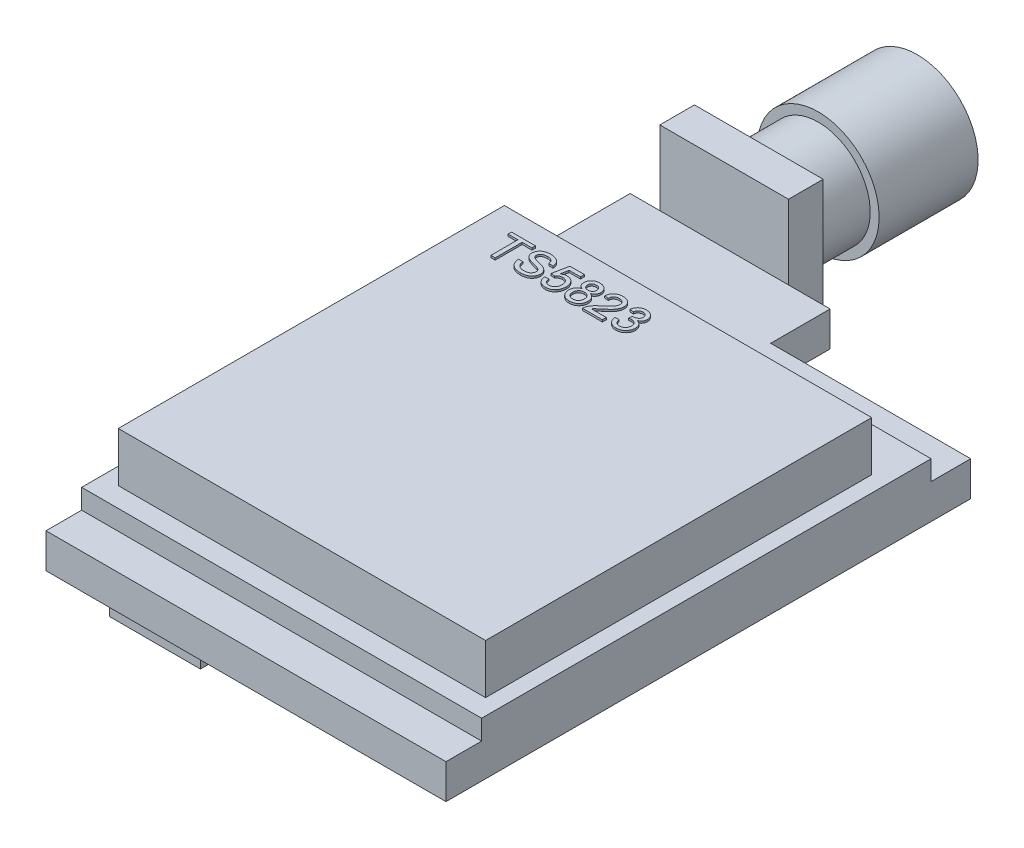
from build123d import *

# Parameters (mm, degrees)
SKETCH_1_W                 = 20.2
SKETCH_1_H                 = 29.5
MAIN_PCB_DEPTH             = 1.75
SKETCH_2_W                 = 20.2
SKETCH_2_H                 = 22.7
RADIO_MODULE_PCB_DEPTH     = 1
SKETCH_3_W                 = 18.55
SKETCH_3_H                 = 19.5
RADIO_MODULE_DEPTH         = 2.5
SKETCH_4_W                 = 6.5
SKETCH_4_H                 = 6.5
ANTENNA_SOCKET_DEPTH       = 1.75
SKETCH_5_R                 = 2.625
ANTENNA_RING_DEPTH         = 3
SKETCH_6_R                 = 3.075
ANTENNA_NUT_DEPTH          = 5
SKETCH_7_R                 = 2.075
SKETCH_7_R_2               = 0.5
ANTENNA_CONNECTOR_DEPTH    = 2
SKETCH_9_W                 = 1
SKETCH_9_H                 = 4
ANTENNA_LEG_DEPTH          = 1
NAME_TS5823_DEPTH          = 0.1
SKETCH_18_W                = 10.1
SKETCH_18_H                = 3
PCB_CUT_OUT_DEPTH          = 6.5
SKETCH_19_W                = 5.5
SKETCH_19_H                = 9.4
EXTRUDE_1_DEPTH            = 2.5
SKETCH_21_W                = 2
SKETCH_21_H                = 0.8
JIMPES_SWITCH_DEPTH        = 0.4
PATTERN_LINEAR_1_COUNT     = 6
PATTERN_LINEAR_1_PITCH     = 1.5
SKETCH_22_W                = 4.6
SKETCH_22_H                = 7.2
EXTRUDE_2_DEPTH            = 3
SKETCH_23_W                = 6.2
SKETCH_23_H                = 2
CUT_EXTRUDE_4_DEPTH        = 4
SKETCH_24_W                = 0.4
SKETCH_24_H                = 0.6
EXTRUDE_3_DEPTH            = 3
PATTERN_LINEAR_2_COUNT     = 3
PATTERN_LINEAR_2_PITCH     = 1
PATTERN_LINEAR_2_COL_COUNT = 3
PATTERN_LINEAR_2_COL_PITCH = 1


with BuildPart() as part:
    # Эскиз1 → main-pcb (new body)
    with BuildSketch(Plane(origin=(0, 0, 0), x_dir=(1, 0, 0), z_dir=(0, 1, 0))):
        Rectangle(SKETCH_1_W, SKETCH_1_H)
    extrude(amount=MAIN_PCB_DEPTH)

    # Эскиз2 → radio-module-pcb (add)
    with BuildSketch(Plane(origin=(0, 1.75, 0), x_dir=(1, 0, 0), z_dir=(0, 1, 0))):
        with Locations((0, -1.6)):
            Rectangle(SKETCH_2_W, SKETCH_2_H)
    extrude(amount=RADIO_MODULE_PCB_DEPTH)

    # Эскиз3 → radio-module (add)
    with BuildSketch(Plane(origin=(0, 2.75, 0), x_dir=(1, 0, 0), z_dir=(0, 1, 0))):
        with Locations((0.025, -2.2)):
            Rectangle(SKETCH_3_W, SKETCH_3_H)
    extrude(amount=RADIO_MODULE_DEPTH)

    # Эскиз4 → antenna-socket (add)
    with BuildSketch(Plane(origin=(0, 0, -14.75), x_dir=(-1, 0, 0), z_dir=(0, 0, -1))):
        with Locations((5.35, 2.25)):
            Rectangle(SKETCH_4_W, SKETCH_4_H)
    extrude(amount=ANTENNA_SOCKET_DEPTH)

    # Эскиз5 → antenna-ring (add)
    with BuildSketch(Plane(origin=(0, 0, -16.5), x_dir=(-1, 0, 0), z_dir=(0, 0, -1))):
        with Locations((5.35, 2.25)):
            Circle(SKETCH_5_R)
    extrude(amount=ANTENNA_RING_DEPTH)

    # Эскиз6 → antenna-nut (add)
    with BuildSketch(Plane(origin=(0, 0, -19.5), x_dir=(-1, 0, 0), z_dir=(0, 0, -1))):
        with Locations((5.35, 2.25)):
            Circle(SKETCH_6_R)
    extrude(amount=ANTENNA_NUT_DEPTH)

    # Эскиз7 → antenna-connector (cut)
    with BuildSketch(Plane(origin=(0, 0, -24.5), x_dir=(-1, 0, 0), z_dir=(0, 0, -1))):
        with Locations((5.35, 2.25)):
            Circle(SKETCH_7_R)
        with Locations((5.35, 2.25)):
            Circle(SKETCH_7_R_2, mode=Mode.SUBTRACT)
    extrude(amount=-ANTENNA_CONNECTOR_DEPTH, mode=Mode.SUBTRACT)

    # Эскиз9 → antenna-leg (add)
    with BuildSketch(Plane.XZ):
        with Locations((-2.6, -12.75)):
            Rectangle(SKETCH_9_W, SKETCH_9_H)
        with Locations((-8.1, -12.75)):
            Rectangle(SKETCH_9_W, SKETCH_9_H)
    extrude(amount=ANTENNA_LEG_DEPTH)

    # Эскиз17 → NAME-TS5823 (add)
    with BuildSketch(Plane(origin=(0, 5.25, 0), x_dir=(1, 0, 0), z_dir=(0, 1, 0))):
        Polygon((-7.31086753, 4.929179158), (-7.31086753, 6.29236369), (-7.804774969, 6.29236369), (-7.804774969, 6.470170369), (-6.599640817, 6.470170369), (-6.599640817, 6.29236369), (-7.093548257, 6.29236369), (-7.093548257, 4.929179158), align=None)
        with BuildLine():
            Line((-6.441590437, 5.462599192), (-6.224271163, 5.462599192))
            add(Edge.make_bspline(
                [(-6.224271163, 5.462599192), (-6.221880777, 5.44308691), (-6.217288717, 5.405602765), (-6.204448859, 5.352474632), (-6.187923132, 5.304706988), (-6.167332532, 5.261665872), (-6.140246383, 5.223867344), (-6.107612232, 5.18977365), (-6.067979832, 5.160250575), (-6.023243887, 5.133976972), (-5.973420529, 5.113348039), (-5.92022965, 5.098055471), (-5.863924926, 5.088994502), (-5.825370916, 5.087826129), (-5.805684608, 5.087229538)],
                knots=[0, 0, 0, 0, 5.8935e-05, 0.000113218, 0.000163594, 0.000210394, 0.000255789, 0.000302509, 0.000351407, 0.000403557, 0.000457792, 0.000512703, 0.000569289, 0.00062833, 0.00062833, 0.00062833, 0.00062833], degree=3))
            add(Edge.make_bspline(
                [(-5.805684608, 5.087229538), (-5.788263922, 5.087551977), (-5.754296957, 5.088180669), (-5.705159945, 5.095732822), (-5.658921874, 5.106445347), (-5.616443283, 5.12264972), (-5.57788087, 5.142326909), (-5.544393735, 5.16612693), (-5.515804201, 5.192966816), (-5.493416523, 5.223553515), (-5.47582921, 5.255603261), (-5.462927098, 5.288547093), (-5.455241575, 5.32220216), (-5.454262239, 5.344847025), (-5.453775558, 5.356100401)],
                knots=[0, 0, 0, 0, 5.2214e-05, 0.000101807, 0.000148825, 0.000194349, 0.00023784, 0.000278354, 0.000317218, 0.00035494, 0.00039155, 0.000426633, 0.000460785, 0.000494523, 0.000494523, 0.000494523, 0.000494523], degree=3))
            add(Edge.make_bspline(
                [(-5.453775558, 5.356100401), (-5.454295829, 5.367239786), (-5.455312699, 5.3890117), (-5.461939356, 5.420708887), (-5.474534255, 5.44972102), (-5.490877584, 5.477232238), (-5.513613945, 5.502385288), (-5.54233877, 5.525561579), (-5.577684942, 5.546573429), (-5.604065541, 5.558080743), (-5.617999781, 5.564158909)],
                knots=[0, 0, 0, 0, 3.343e-05, 6.5339e-05, 9.647e-05, 0.000127917, 0.000160935, 0.000197576, 0.000238287, 0.000283865, 0.000283865, 0.000283865, 0.000283865], degree=3))
            add(Edge.make_bspline(
                [(-5.617999781, 5.564158909), (-5.623428768, 5.566386786), (-5.635693834, 5.571419965), (-5.656715581, 5.578083026), (-5.681660547, 5.586699045), (-5.711128014, 5.595572141), (-5.74496023, 5.604958637), (-5.783100867, 5.615582727), (-5.825528612, 5.626880864), (-5.871040143, 5.638906501), (-5.916992921, 5.65113473), (-5.960895431, 5.663374411), (-6.001287827, 5.675799254), (-6.038500979, 5.687762663), (-6.072343034, 5.699775429), (-6.102910044, 5.711508668), (-6.130240119, 5.722724329), (-6.146932289, 5.730971032), (-6.15481543, 5.734865668)],
                knots=[0, 0, 0, 0, 1.7598e-05, 3.9757e-05, 6.6114e-05, 9.6776e-05, 0.000132055, 0.000171448, 0.000215552, 0.000263772, 0.000312668, 0.000358208, 0.00040049, 0.000439441, 0.000475468, 0.000508202, 0.000537671, 0.000564042, 0.000564042, 0.000564042, 0.000564042], degree=3))
            add(Edge.make_bspline(
                [(-6.15481543, 5.734865668), (-6.172952338, 5.744663748), (-6.20796129, 5.763576593), (-6.255079463, 5.797392812), (-6.294781307, 5.834918166), (-6.326899328, 5.876098242), (-6.352068964, 5.920236585), (-6.369050807, 5.967408232), (-6.380681968, 6.016756928), (-6.38176893, 6.050691894), (-6.382321544, 6.067944498)],
                knots=[0, 0, 0, 0, 6.1798e-05, 0.000119286, 0.000173435, 0.000225119, 0.000275431, 0.000325146, 0.000375102, 0.000426765, 0.000426765, 0.000426765, 0.000426765], degree=3))
            add(Edge.make_bspline(
                [(-6.382321544, 6.067944498), (-6.381588115, 6.087048842), (-6.380129332, 6.125047244), (-6.36718912, 6.18080753), (-6.346549235, 6.234463757), (-6.323054778, 6.277062222), (-6.30014249, 6.309274991), (-6.28114803, 6.332474039), (-6.259842027, 6.353918439), (-6.236880634, 6.373907542), (-6.211853391, 6.392142687), (-6.185381227, 6.409373316), (-6.156505997, 6.424183455), (-6.115932006, 6.443033418), (-6.061653782, 6.46185687), (-5.993324286, 6.478259121), (-5.921409736, 6.487918065), (-5.872391089, 6.489247662), (-5.847358049, 6.489926666)],
                knots=[0, 0, 0, 0, 5.7249e-05, 0.000113868, 0.000170737, 0.000229324, 0.000259216, 0.000289254, 0.000319159, 0.000349796, 0.000380481, 0.000411994, 0.000444443, 0.000477732, 0.000546173, 0.000616328, 0.000688275, 0.000763364, 0.000763364, 0.000763364, 0.000763364], degree=3))
            add(Edge.make_bspline(
                [(-5.847358049, 6.489926666), (-5.819957723, 6.48929883), (-5.766604009, 6.488076311), (-5.689079554, 6.477905176), (-5.616770461, 6.460438662), (-5.560063189, 6.440886652), (-5.518140167, 6.421092895), (-5.488356884, 6.405648027), (-5.460712108, 6.387790946), (-5.43495698, 6.368466791), (-5.41085227, 6.347684387), (-5.389017523, 6.324949389), (-5.368504614, 6.301037475), (-5.344399086, 6.266707457), (-5.318408218, 6.221271874), (-5.295935574, 6.162408271), (-5.280496605, 6.100282571), (-5.277493371, 6.057333484), (-5.27596888, 6.035531822)],
                knots=[0, 0, 0, 0, 8.2182e-05, 0.000160025, 0.000233998, 0.000305077, 0.000339465, 0.000373022, 0.000405647, 0.000438059, 0.000469567, 0.000501002, 0.000532543, 0.000563978, 0.000626734, 0.00068899, 0.000752481, 0.000817937, 0.000817937, 0.000817937, 0.000817937], degree=3))
            Line((-5.27596888, 6.035531822), (-5.493288153, 6.035531822))
            add(Edge.make_bspline(
                [(-5.493288153, 6.035531822), (-5.494668968, 6.04656628), (-5.497370813, 6.068157445), (-5.504073731, 6.099413905), (-5.513469875, 6.128443497), (-5.524475638, 6.155516945), (-5.537816928, 6.180352652), (-5.553369011, 6.203189098), (-5.571321279, 6.223757228), (-5.591211801, 6.242600533), (-5.613645842, 6.259007792), (-5.63850813, 6.273249796), (-5.665840632, 6.285281028), (-5.695619268, 6.295135), (-5.727849935, 6.302775384), (-5.76260594, 6.308395797), (-5.799873852, 6.311274262), (-5.825539681, 6.311833114), (-5.838714668, 6.312119988)],
                knots=[0, 0, 0, 0, 3.3353e-05, 6.5262e-05, 9.5721e-05, 0.000124786, 0.000152822, 0.000180136, 0.000207491, 0.000234572, 0.00026217, 0.000290657, 0.00032037, 0.000351607, 0.000384626, 0.000419643, 0.000457122, 0.000496654, 0.000496654, 0.000496654, 0.000496654], degree=3))
            add(Edge.make_bspline(
                [(-5.838714668, 6.312119988), (-5.852409453, 6.312016763), (-5.878919187, 6.311816945), (-5.917242015, 6.308174516), (-5.952762323, 6.303176973), (-5.985419101, 6.295805172), (-6.015105369, 6.286155461), (-6.042261715, 6.275012258), (-6.066128139, 6.26089091), (-6.08726101, 6.245161565), (-6.105490787, 6.227757914), (-6.121202154, 6.209418673), (-6.135097645, 6.190682663), (-6.145894748, 6.170525761), (-6.154685213, 6.149711339), (-6.160356029, 6.127848156), (-6.164371099, 6.105340622), (-6.164788972, 6.08998328), (-6.16500227, 6.082144337)],
                knots=[0, 0, 0, 0, 4.1066e-05, 7.9495e-05, 0.00011538, 0.000148629, 0.00017977, 0.000208954, 0.000236485, 0.000262723, 0.000287834, 0.000311908, 0.000335126, 0.000357643, 0.000380344, 0.000402735, 0.000425267, 0.00044876, 0.00044876, 0.00044876, 0.00044876], degree=3))
            add(Edge.make_bspline(
                [(-6.16500227, 6.082144337), (-6.164440666, 6.068886326), (-6.163350644, 6.043153749), (-6.152219927, 6.006595514), (-6.135100806, 5.973270314), (-6.118235745, 5.955138242), (-6.109746376, 5.946011099)],
                knots=[0, 0, 0, 0, 3.9658e-05, 7.6973e-05, 0.000113707, 0.00015094, 0.00015094, 0.00015094, 0.00015094], degree=3))
            add(Edge.make_bspline(
                [(-6.109746376, 5.946011099), (-6.104394768, 5.941449789), (-6.092560018, 5.931362734), (-6.070539641, 5.918013698), (-6.043237639, 5.904526198), (-6.010471585, 5.89111858), (-5.972297855, 5.877628075), (-5.928778022, 5.863737942), (-5.879746325, 5.849942443), (-5.826697004, 5.836648197), (-5.773104819, 5.823300507), (-5.722174227, 5.810003689), (-5.675411322, 5.797401965), (-5.632890298, 5.785111047), (-5.594567143, 5.77316569), (-5.560575045, 5.761315623), (-5.530638995, 5.750416568), (-5.512299627, 5.742748192), (-5.503783686, 5.739187358)],
                knots=[0, 0, 0, 0, 2.1068e-05, 4.6591e-05, 7.6962e-05, 0.00011239, 0.000152716, 0.000198404, 0.000249414, 0.000305492, 0.000362467, 0.000415103, 0.000463403, 0.000507756, 0.000547882, 0.000583807, 0.000615746, 0.000643434, 0.000643434, 0.000643434, 0.000643434], degree=3))
            add(Edge.make_bspline(
                [(-5.503783686, 5.739187358), (-5.492704014, 5.734078918), (-5.470956475, 5.724051906), (-5.440148173, 5.706932291), (-5.411400685, 5.689154492), (-5.384946272, 5.670239872), (-5.360870472, 5.650148643), (-5.338904091, 5.629111007), (-5.31891446, 5.607245199), (-5.301708158, 5.583851386), (-5.286258664, 5.559875251), (-5.272739328, 5.534981696), (-5.261853818, 5.509024328), (-5.252306547, 5.482316038), (-5.245439321, 5.454559753), (-5.24005403, 5.42603583), (-5.23691288, 5.396610197), (-5.236609799, 5.37668718), (-5.236456284, 5.366595934)],
                knots=[0, 0, 0, 0, 3.659e-05, 7.182e-05, 0.000105654, 0.00013795, 0.000169293, 0.000199641, 0.000229148, 0.000258042, 0.000286642, 0.000314678, 0.00034289, 0.000371006, 0.000399681, 0.000428562, 0.000458049, 0.000488315, 0.000488315, 0.000488315, 0.000488315], degree=3))
            add(Edge.make_bspline(
                [(-5.236456284, 5.366595934), (-5.237260499, 5.346456549), (-5.238857131, 5.306473177), (-5.252604711, 5.247535837), (-5.274201433, 5.190425884), (-5.299528938, 5.14510599), (-5.323471086, 5.110488177), (-5.34358362, 5.085606476), (-5.365887263, 5.062599551), (-5.389832924, 5.04074664), (-5.415606516, 5.020493613), (-5.443425328, 5.001833574), (-5.472995746, 4.984572274), (-5.515221558, 4.963538368), (-5.571304452, 4.941534906), (-5.6427428, 4.923211168), (-5.718030166, 4.911324106), (-5.769727119, 4.910065367), (-5.796115152, 4.90942286)],
                knots=[0, 0, 0, 0, 6.035e-05, 0.000119815, 0.000180585, 0.00024304, 0.00027498, 0.000306799, 0.000338893, 0.000371016, 0.000403993, 0.000437127, 0.000471434, 0.000506638, 0.000578579, 0.000651656, 0.000727533, 0.000806645, 0.000806645, 0.000806645, 0.000806645], degree=3))
            add(Edge.make_bspline(
                [(-5.796115152, 4.90942286), (-5.812893211, 4.90956132), (-5.845759031, 4.909832544), (-5.894051684, 4.913117149), (-5.940331416, 4.917868492), (-5.984552809, 4.92494567), (-6.026577191, 4.934230543), (-6.066555409, 4.945379881), (-6.104582223, 4.958220642), (-6.140524767, 4.973321155), (-6.174289215, 4.990866302), (-6.206482685, 5.009793075), (-6.236578955, 5.03124746), (-6.264641381, 5.054892334), (-6.291381005, 5.080044616), (-6.315689549, 5.107731506), (-6.338393441, 5.137143339), (-6.358973904, 5.168549304), (-6.377359415, 5.201538506), (-6.393893228, 5.235556928), (-6.407823196, 5.270851346), (-6.419049425, 5.307243383), (-6.428558609, 5.344489503), (-6.435153009, 5.382900461), (-6.440001433, 5.422355659), (-6.44105764, 5.449105446), (-6.441590437, 5.462599192)],
                knots=[0, 0, 0, 0, 5.0325e-05, 9.858e-05, 0.000145147, 0.000189857, 0.000232848, 0.000274191, 0.000314313, 0.000353185, 0.000391013, 0.000428389, 0.000465135, 0.000501734, 0.000538416, 0.000575151, 0.000612135, 0.000649807, 0.000687675, 0.000725368, 0.000763201, 0.000801375, 0.000839558, 0.000878434, 0.000918217, 0.000958713, 0.000958713, 0.000958713, 0.000958713], degree=3))
        make_face()
        with BuildLine():
            Line((-5.019137011, 5.344061407), (-4.821574035, 5.363817704))
            add(Edge.make_bspline(
                [(-4.821574035, 5.363817704), (-4.819617852, 5.352686115), (-4.81581277, 5.331033442), (-4.808561767, 5.299690556), (-4.799144778, 5.270572139), (-4.788563754, 5.243426009), (-4.775986422, 5.218539202), (-4.762358779, 5.195518768), (-4.746287759, 5.175181861), (-4.729391239, 5.156464841), (-4.710846017, 5.139971837), (-4.690473146, 5.126067666), (-4.668841042, 5.113937118), (-4.645686234, 5.104005165), (-4.620973236, 5.096735498), (-4.595016576, 5.090986439), (-4.567482017, 5.088089516), (-4.548695376, 5.087519863), (-4.539120718, 5.087229538)],
                knots=[0, 0, 0, 0, 3.3906e-05, 6.5952e-05, 9.6411e-05, 0.000125645, 0.000153256, 0.000179991, 0.000205738, 0.000230864, 0.000255577, 0.000279981, 0.000304717, 0.000329888, 0.000355375, 0.000381894, 0.000409541, 0.000438276, 0.000438276, 0.000438276, 0.000438276], degree=3))
            add(Edge.make_bspline(
                [(-4.539120718, 5.087229538), (-4.527374759, 5.087513355), (-4.504405024, 5.08806837), (-4.47098841, 5.092762468), (-4.439423712, 5.100502492), (-4.409861962, 5.11133408), (-4.381956606, 5.124804442), (-4.356633387, 5.142246106), (-4.332511543, 5.16185226), (-4.311143321, 5.185226559), (-4.291692235, 5.210673387), (-4.274904486, 5.238449683), (-4.260771573, 5.268165584), (-4.248873205, 5.299815393), (-4.240087128, 5.333579914), (-4.233624259, 5.369279526), (-4.229475355, 5.40693697), (-4.229084647, 5.432747888), (-4.228885108, 5.445929816)],
                knots=[0, 0, 0, 0, 3.5225e-05, 6.8884e-05, 0.000101002, 0.000132545, 0.000163193, 0.000193672, 0.00022458, 0.000256249, 0.000288415, 0.00032055, 0.000353411, 0.000387012, 0.00042183, 0.000457916, 0.00049579, 0.000535322, 0.000535322, 0.000535322, 0.000535322], degree=3))
            add(Edge.make_bspline(
                [(-4.228885108, 5.445929816), (-4.229111901, 5.458492022), (-4.229553519, 5.482953552), (-4.233272667, 5.518573605), (-4.239547308, 5.552067235), (-4.247666105, 5.5838036), (-4.258856843, 5.613286779), (-4.272129688, 5.640944251), (-4.288389481, 5.666189042), (-4.306479574, 5.689807183), (-4.327140744, 5.710979895), (-4.35065212, 5.728857569), (-4.376091364, 5.744504144), (-4.40397085, 5.75719254), (-4.434306993, 5.766619542), (-4.466798337, 5.773872771), (-4.501782026, 5.777687673), (-4.525839052, 5.778356465), (-4.538194642, 5.778699953)],
                knots=[0, 0, 0, 0, 3.7681e-05, 7.3373e-05, 0.000107279, 0.00013985, 0.000171499, 0.000201734, 0.000231707, 0.000261407, 0.000290876, 0.000320143, 0.00034979, 0.00038032, 0.000411755, 0.000444936, 0.000480048, 0.000517123, 0.000517123, 0.000517123, 0.000517123], degree=3))
            add(Edge.make_bspline(
                [(-4.538194642, 5.778699953), (-4.553558219, 5.778250539), (-4.583022082, 5.777388663), (-4.625358623, 5.770138013), (-4.66389911, 5.758425511), (-4.698207187, 5.740969452), (-4.728859759, 5.720115322), (-4.756493616, 5.696517928), (-4.781336628, 5.670193224), (-4.794964031, 5.650373777), (-4.801817738, 5.64040587)],
                knots=[0, 0, 0, 0, 4.6061e-05, 8.8335e-05, 0.000128462, 0.000166426, 0.000203327, 0.000239455, 0.000275276, 0.000311521, 0.000311521, 0.000311521, 0.000311521], degree=3))
            Line((-4.801817738, 5.64040587), (-4.999380714, 5.660162168))
            Line((-4.999380714, 5.660162168), (-4.841330333, 6.450414071))
            Line((-4.841330333, 6.450414071), (-4.110347323, 6.450414071))
            Line((-4.110347323, 6.450414071), (-4.110347323, 6.252851095))
            Line((-4.110347323, 6.252851095), (-4.679884339, 6.252851095))
            Line((-4.679884339, 6.252851095), (-4.758292145, 5.853712146))
            add(Edge.make_bspline(
                [(-4.758292145, 5.853712146), (-4.747391149, 5.861892406), (-4.725983317, 5.877957143), (-4.692590937, 5.898991798), (-4.658721081, 5.91672261), (-4.624570914, 5.931242654), (-4.589869166, 5.942553743), (-4.554825245, 5.950412165), (-4.519319831, 5.955723349), (-4.495511357, 5.956244793), (-4.483556131, 5.956506632)],
                knots=[0, 0, 0, 0, 4.0875e-05, 8.0271e-05, 0.000118242, 0.000155452, 0.000191473, 0.000227568, 0.000263104, 0.000298945, 0.000298945, 0.000298945, 0.000298945], degree=3))
            add(Edge.make_bspline(
                [(-4.483556131, 5.956506632), (-4.467997216, 5.956098976), (-4.437357939, 5.955296202), (-4.392209903, 5.948700408), (-4.349040787, 5.937503611), (-4.307511973, 5.922423157), (-4.26817107, 5.902431439), (-4.230619582, 5.878225714), (-4.195009116, 5.84960646), (-4.16154099, 5.817113664), (-4.131184069, 5.781043244), (-4.104013633, 5.742571589), (-4.081822306, 5.7009286), (-4.063157876, 5.657201585), (-4.049080764, 5.610672747), (-4.038395744, 5.562002427), (-4.032682819, 5.510582133), (-4.031782793, 5.475576883), (-4.031322132, 5.457660118)],
                knots=[0, 0, 0, 0, 4.6663e-05, 9.189e-05, 0.000136513, 0.000180267, 0.000224167, 0.000268607, 0.000314069, 0.000361003, 0.000408315, 0.000455327, 0.000502013, 0.0005496, 0.000597737, 0.000647627, 0.000698898, 0.000752653, 0.000752653, 0.000752653, 0.000752653], degree=3))
            add(Edge.make_bspline(
                [(-4.031322132, 5.457660118), (-4.031671937, 5.440564578), (-4.0323629, 5.40679601), (-4.038025486, 5.357031782), (-4.047353251, 5.309080031), (-4.059840555, 5.262798757), (-4.076712578, 5.218450803), (-4.097176763, 5.175892921), (-4.120783348, 5.134681033), (-4.139714604, 5.109276283), (-4.149242533, 5.096490303)],
                knots=[0, 0, 0, 0, 5.1276e-05, 0.000101285, 0.000150021, 0.000197725, 0.000244911, 0.000292132, 0.000339305, 0.000387104, 0.000387104, 0.000387104, 0.000387104], degree=3))
            add(Edge.make_bspline(
                [(-4.149242533, 5.096490303), (-4.161347501, 5.08156504), (-4.185159271, 5.052205444), (-4.226389092, 5.014098447), (-4.270711734, 4.981712744), (-4.318390967, 4.955401707), (-4.369106704, 4.934258561), (-4.423481974, 4.920188591), (-4.480859746, 4.910740049), (-4.5202507, 4.909867964), (-4.540355487, 4.90942286)],
                knots=[0, 0, 0, 0, 5.759e-05, 0.000113286, 0.000167868, 0.000221897, 0.000276299, 0.000332234, 0.00039004, 0.000450299, 0.000450299, 0.000450299, 0.000450299], degree=3))
            add(Edge.make_bspline(
                [(-4.540355487, 4.90942286), (-4.556938747, 4.909759249), (-4.589378931, 4.910417293), (-4.636877134, 4.916138014), (-4.682053541, 4.925260548), (-4.724922306, 4.938345086), (-4.76561258, 4.954878623), (-4.803651394, 4.975881885), (-4.839698868, 4.999908309), (-4.872962079, 5.027698144), (-4.903269196, 5.058694493), (-4.930424987, 5.092240612), (-4.954061963, 5.128358373), (-4.974168713, 5.166831658), (-4.990926761, 5.207623568), (-5.00374733, 5.251012525), (-5.013902288, 5.296572815), (-5.017373808, 5.3280659), (-5.019137011, 5.344061407)],
                knots=[0, 0, 0, 0, 4.9734e-05, 9.729e-05, 0.0001433, 0.000187829, 0.000231569, 0.000274805, 0.000317956, 0.000361353, 0.000404575, 0.000447819, 0.000490628, 0.000533846, 0.000577872, 0.000622696, 0.000669438, 0.000717682, 0.000717682, 0.000717682, 0.000717682], degree=3))
        make_face()
        with BuildLine():
            add(Edge.make_bspline(
                [(-3.541118999, 5.774378263), (-3.559864236, 5.781711507), (-3.595805073, 5.795771766), (-3.644279996, 5.823910301), (-3.68530627, 5.856279981), (-3.718380147, 5.893661379), (-3.743588453, 5.935281718), (-3.761739431, 5.980610342), (-3.772370777, 6.02989978), (-3.773769985, 6.063982157), (-3.774490264, 6.081526952)],
                knots=[0, 0, 0, 0, 6.0314e-05, 0.000115643, 0.000167468, 0.000216458, 0.000264529, 0.000312737, 0.000362325, 0.000414933, 0.000414933, 0.000414933, 0.000414933], degree=3))
            add(Edge.make_bspline(
                [(-3.774490264, 6.081526952), (-3.774151262, 6.095026898), (-3.773485791, 6.121527714), (-3.76773597, 6.160413176), (-3.758526803, 6.197675176), (-3.745456841, 6.233208547), (-3.729082321, 6.267305761), (-3.708420437, 6.299342142), (-3.684670886, 6.330223103), (-3.656849414, 6.358700342), (-3.626190634, 6.384782736), (-3.59298239, 6.407993505), (-3.556970573, 6.426974272), (-3.518755602, 6.442843792), (-3.478148524, 6.455267948), (-3.435006298, 6.463729491), (-3.389481009, 6.46911166), (-3.358286, 6.469811969), (-3.342321254, 6.470170369)],
                knots=[0, 0, 0, 0, 4.0481e-05, 7.9466e-05, 0.000117649, 0.000155442, 0.000192856, 0.000230879, 0.000269595, 0.000309545, 0.000350059, 0.000390219, 0.000430821, 0.000471925, 0.000514206, 0.000557977, 0.000603657, 0.00065154, 0.00065154, 0.00065154, 0.00065154], degree=3))
            add(Edge.make_bspline(
                [(-3.342321254, 6.470170369), (-3.326254779, 6.469808331), (-3.294959099, 6.469103121), (-3.249191944, 6.463793268), (-3.205777462, 6.454893623), (-3.164741214, 6.442267267), (-3.126018504, 6.426123711), (-3.089863779, 6.406281161), (-3.055904849, 6.383066884), (-3.025009691, 6.356204042), (-2.99689878, 6.327039732), (-2.972543331, 6.295794884), (-2.951654437, 6.263198576), (-2.934392905, 6.229052777), (-2.921622759, 6.19296866), (-2.91188904, 6.155626064), (-2.906243032, 6.116581288), (-2.905560741, 6.090085343), (-2.90521317, 6.076587878)],
                knots=[0, 0, 0, 0, 4.8192e-05, 9.3872e-05, 0.000138006, 0.000180969, 0.000222476, 0.000263643, 0.000304486, 0.000345636, 0.000386246, 0.000425828, 0.000464277, 0.000502241, 0.000540325, 0.000578883, 0.000617867, 0.000658348, 0.000658348, 0.000658348, 0.000658348], degree=3))
            add(Edge.make_bspline(
                [(-2.90521317, 6.076587878), (-2.905777788, 6.059647776), (-2.906884896, 6.026431424), (-2.918166828, 5.978549775), (-2.935750683, 5.933849857), (-2.961164659, 5.893183571), (-2.993350515, 5.856130926), (-3.033290596, 5.823920655), (-3.080378339, 5.795826096), (-3.115411726, 5.781719991), (-3.133645361, 5.774378263)],
                knots=[0, 0, 0, 0, 5.0739e-05, 9.949e-05, 0.000146724, 0.000194269, 0.000242619, 0.000293291, 0.000347555, 0.00040645, 0.00040645, 0.00040645, 0.00040645], degree=3))
            add(Edge.make_bspline(
                [(-3.133645361, 5.774378263), (-3.122141121, 5.770473119), (-3.099597802, 5.76282073), (-3.067728274, 5.747942128), (-3.037724071, 5.731899463), (-3.009415997, 5.714533269), (-2.983848972, 5.694552063), (-2.960170005, 5.67313725), (-2.938478652, 5.649987055), (-2.919071195, 5.624904582), (-2.901744289, 5.598416269), (-2.886911083, 5.570457537), (-2.874313525, 5.541426341), (-2.863547218, 5.51118806), (-2.855683282, 5.479529697), (-2.850180992, 5.446596739), (-2.846689943, 5.412562756), (-2.846195417, 5.389447617), (-2.845944278, 5.377708851)],
                knots=[0, 0, 0, 0, 3.6422e-05, 7.1371e-05, 0.000105345, 0.000138492, 0.000170846, 0.000202533, 0.000234202, 0.000265879, 0.000297558, 0.000329045, 0.000360702, 0.000392432, 0.000425224, 0.000458414, 0.000492539, 0.000527752, 0.000527752, 0.000527752, 0.000527752], degree=3))
            add(Edge.make_bspline(
                [(-2.845944278, 5.377708851), (-2.846336892, 5.361529652), (-2.847110372, 5.329655396), (-2.85390641, 5.282867729), (-2.864189117, 5.23792179), (-2.879182491, 5.195007448), (-2.898332754, 5.154094367), (-2.922021861, 5.115241956), (-2.950017059, 5.078490182), (-2.981492537, 5.043724809), (-3.016682103, 5.012298418), (-3.054750695, 4.984604833), (-3.095841152, 4.961407925), (-3.139454905, 4.942200969), (-3.185800792, 4.927315648), (-3.234819239, 4.916892768), (-3.286493934, 4.910686402), (-3.32182749, 4.909849684), (-3.339851717, 4.90942286)],
                knots=[0, 0, 0, 0, 4.8513e-05, 9.5574e-05, 0.000141548, 0.000186651, 0.00023167, 0.000276828, 0.000322886, 0.000370084, 0.000417305, 0.000464171, 0.000511037, 0.000558584, 0.000606907, 0.000656797, 0.000708717, 0.000762781, 0.000762781, 0.000762781, 0.000762781], degree=3))
            add(Edge.make_bspline(
                [(-3.339851717, 4.90942286), (-3.357874141, 4.909858882), (-3.393204163, 4.910713633), (-3.444926071, 4.916793119), (-3.493874384, 4.927688497), (-3.540160011, 4.942588947), (-3.584034034, 4.961275873), (-3.624848528, 4.984995467), (-3.663165784, 5.012653966), (-3.698379818, 5.044274738), (-3.730116748, 5.079036403), (-3.757742907, 5.116330943), (-3.781291384, 5.155584409), (-3.80067127, 5.197018081), (-3.815443162, 5.240632336), (-3.825810252, 5.286263432), (-3.832618591, 5.3338765), (-3.833373611, 5.366366052), (-3.833759157, 5.382956618)],
                knots=[0, 0, 0, 0, 5.4064e-05, 0.000105984, 0.00015594, 0.000204263, 0.000251687, 0.000298706, 0.000345572, 0.000393229, 0.000440427, 0.000486547, 0.000532234, 0.000577532, 0.000623511, 0.000670086, 0.000717759, 0.000767505, 0.000767505, 0.000767505, 0.000767505], degree=3))
            add(Edge.make_bspline(
                [(-3.833759157, 5.382956618), (-3.833491173, 5.395309529), (-3.832965344, 5.419548078), (-3.829753228, 5.455099433), (-3.823351544, 5.488983612), (-3.815105768, 5.521400292), (-3.804636211, 5.552430573), (-3.791720021, 5.581830774), (-3.776049354, 5.609529836), (-3.758246449, 5.635707997), (-3.738086654, 5.660181476), (-3.715896712, 5.682735954), (-3.691596019, 5.703114889), (-3.665730654, 5.721913488), (-3.637216436, 5.737801992), (-3.607113797, 5.752382656), (-3.574905195, 5.764817258), (-3.552493854, 5.771159344), (-3.541118999, 5.774378263)],
                knots=[0, 0, 0, 0, 3.7064e-05, 7.2725e-05, 0.000106934, 0.000140402, 0.000173006, 0.00020507, 0.000236582, 0.000268348, 0.000299928, 0.000331579, 0.00036312, 0.000394986, 0.00042734, 0.000460891, 0.000495287, 0.000530739, 0.000530739, 0.000530739, 0.000530739], degree=3))
        make_face()
        with BuildLine():
            add(Edge.make_bspline(
                [(-3.576927288, 6.080600876), (-3.576340923, 6.064873478), (-3.575207807, 6.034481168), (-3.562885042, 5.991311118), (-3.543615813, 5.952532307), (-3.521026024, 5.924410811), (-3.49936809, 5.905250182), (-3.481291561, 5.89245731), (-3.461537411, 5.88159642), (-3.43996253, 5.873154652), (-3.417089462, 5.865675771), (-3.392129348, 5.86149562), (-3.36566886, 5.858097405), (-3.347376107, 5.857851295), (-3.337999564, 5.857725144)],
                knots=[0, 0, 0, 0, 4.7067e-05, 9.0955e-05, 0.000133475, 0.000176285, 0.000198152, 0.000220078, 0.000242596, 0.000265582, 0.000289503, 0.000314629, 0.000341356, 0.000369462, 0.000369462, 0.000369462, 0.000369462], degree=3))
            add(Edge.make_bspline(
                [(-3.337999564, 5.857725144), (-3.32883, 5.857855957), (-3.310949851, 5.858111036), (-3.285085316, 5.86143997), (-3.260643421, 5.865886076), (-3.237985345, 5.872623465), (-3.216849501, 5.881384037), (-3.197579656, 5.892183659), (-3.179599162, 5.904595523), (-3.158577458, 5.923902539), (-3.136018842, 5.951039109), (-3.116685038, 5.988085616), (-3.104637034, 6.028616693), (-3.103407332, 6.056848951), (-3.102776146, 6.071340111)],
                knots=[0, 0, 0, 0, 2.7489e-05, 5.3602e-05, 7.8122e-05, 0.000101953, 0.000124369, 0.000146616, 0.000168112, 0.000189749, 0.00023208, 0.000273228, 0.000314358, 0.000357733, 0.000357733, 0.000357733, 0.000357733], degree=3))
            add(Edge.make_bspline(
                [(-3.102776146, 6.071340111), (-3.103536637, 6.086337841), (-3.105024719, 6.115684515), (-3.117043294, 6.157812987), (-3.137277616, 6.195968802), (-3.160392525, 6.223833453), (-3.181786102, 6.244019752), (-3.200089398, 6.256869683), (-3.21976551, 6.267806111), (-3.240889325, 6.276737178), (-3.263491388, 6.283940175), (-3.287632927, 6.288665689), (-3.313212498, 6.291979857), (-3.330785135, 6.292233054), (-3.339851717, 6.29236369)],
                knots=[0, 0, 0, 0, 4.494e-05, 8.7936e-05, 0.00013019, 0.00017363, 0.000195911, 0.000218267, 0.000240515, 0.000263335, 0.000286961, 0.000311541, 0.000337041, 0.000364222, 0.000364222, 0.000364222, 0.000364222], degree=3))
            add(Edge.make_bspline(
                [(-3.339851717, 6.29236369), (-3.348919308, 6.292237279), (-3.366596134, 6.291990846), (-3.392342502, 6.288577225), (-3.41671283, 6.284289788), (-3.439482286, 6.277409243), (-3.460556224, 6.268417971), (-3.480154763, 6.2574754), (-3.498423379, 6.2449537), (-3.519967261, 6.22566754), (-3.542530928, 6.198530355), (-3.562408884, 6.162075526), (-3.574694104, 6.122327458), (-3.576173673, 6.094682013), (-3.576927288, 6.080600876)],
                knots=[0, 0, 0, 0, 2.7181e-05, 5.2987e-05, 7.781e-05, 0.000101345, 0.000124166, 0.000146413, 0.000168592, 0.000190459, 0.000232987, 0.000273735, 0.000314361, 0.000356534, 0.000356534, 0.000356534, 0.000356534], degree=3))
        make_face(mode=Mode.SUBTRACT)
        with BuildLine():
            add(Edge.make_bspline(
                [(-3.636196181, 5.386660923), (-3.63585455, 5.373984201), (-3.635170388, 5.348597363), (-3.629168816, 5.310892529), (-3.618985392, 5.273889829), (-3.605933561, 5.237554309), (-3.587523142, 5.203352536), (-3.563108856, 5.172824937), (-3.532473499, 5.147159173), (-3.497486247, 5.125475761), (-3.459306159, 5.108409051), (-3.419521392, 5.096495907), (-3.379158768, 5.088624297), (-3.351926651, 5.087694511), (-3.338308256, 5.087229538)],
                knots=[0, 0, 0, 0, 3.8014e-05, 7.6129e-05, 0.000114168, 0.000153044, 0.000191723, 0.000230146, 0.000269555, 0.000311013, 0.000353294, 0.0003946, 0.000435408, 0.000476231, 0.000476231, 0.000476231, 0.000476231], degree=3))
            add(Edge.make_bspline(
                [(-3.338308256, 5.087229538), (-3.327078421, 5.087419764), (-3.305262053, 5.087789317), (-3.273460619, 5.092012256), (-3.243496478, 5.098419837), (-3.215232351, 5.10720568), (-3.189084255, 5.119225295), (-3.164626378, 5.133273614), (-3.142108893, 5.150252083), (-3.121538175, 5.169628802), (-3.103123736, 5.191063084), (-3.087349441, 5.214185992), (-3.073589336, 5.238347249), (-3.06235484, 5.264068293), (-3.054230488, 5.291402163), (-3.047961404, 5.319855697), (-3.04417945, 5.349722377), (-3.043734567, 5.370083553), (-3.043507253, 5.38048708)],
                knots=[0, 0, 0, 0, 3.367e-05, 6.5411e-05, 9.6048e-05, 0.000125531, 0.000153991, 0.000182211, 0.000209993, 0.000238383, 0.000266843, 0.000294585, 0.00032223, 0.000350158, 0.000378573, 0.000407636, 0.000437501, 0.000468703, 0.000468703, 0.000468703, 0.000468703], degree=3))
            add(Edge.make_bspline(
                [(-3.043507253, 5.38048708), (-3.043741806, 5.391094817), (-3.044201022, 5.411863074), (-3.047886864, 5.442385266), (-3.054507479, 5.471339398), (-3.063021617, 5.499162881), (-3.074560708, 5.525371668), (-3.088411772, 5.55034156), (-3.105373698, 5.573414407), (-3.123973803, 5.595373536), (-3.145022893, 5.615251623), (-3.168267677, 5.632393249), (-3.192971474, 5.647532208), (-3.219881598, 5.659145067), (-3.248405181, 5.668447233), (-3.278677735, 5.675206327), (-3.310822688, 5.679337982), (-3.332841839, 5.679721235), (-3.344173407, 5.679918466)],
                knots=[0, 0, 0, 0, 3.1819e-05, 6.2297e-05, 9.2029e-05, 0.000120831, 0.000149448, 0.000177782, 0.00020631, 0.000235206, 0.000264032, 0.000292925, 0.000321725, 0.000350748, 0.00038062, 0.000411624, 0.000443672, 0.000477651, 0.000477651, 0.000477651, 0.000477651], degree=3))
            add(Edge.make_bspline(
                [(-3.344173407, 5.679918466), (-3.355197259, 5.679719272), (-3.376807442, 5.679328791), (-3.408201064, 5.675173732), (-3.437921178, 5.66879294), (-3.465706307, 5.659453801), (-3.49190385, 5.647783599), (-3.516034663, 5.633109154), (-3.538529238, 5.616076311), (-3.558700446, 5.596278871), (-3.576900103, 5.574773468), (-3.592635656, 5.551719743), (-3.606536421, 5.527652472), (-3.617085419, 5.50178192), (-3.626014201, 5.474944436), (-3.631596102, 5.446619132), (-3.635564136, 5.417127834), (-3.63598242, 5.396964995), (-3.636196181, 5.386660923)],
                knots=[0, 0, 0, 0, 3.3053e-05, 6.4794e-05, 9.4828e-05, 0.000124113, 0.000152573, 0.000180685, 0.000208653, 0.000237033, 0.000265293, 0.000293036, 0.00032068, 0.000348487, 0.0003767, 0.000405396, 0.000434955, 0.000465849, 0.000465849, 0.000465849, 0.000465849], degree=3))
        make_face(mode=Mode.SUBTRACT)
        with BuildLine():
            Line((-1.680322721, 5.126742133), (-1.680322721, 4.929179158))
            Line((-1.680322721, 4.929179158), (-2.687893897, 4.929179158))
            add(Edge.make_bspline(
                [(-2.687893897, 4.929179158), (-2.687914525, 4.940920881), (-2.687955711, 4.964364971), (-2.683988593, 4.999037294), (-2.677775292, 5.033249659), (-2.670749915, 5.055188689), (-2.667211523, 5.066238472)],
                knots=[0, 0, 0, 0, 3.5196e-05, 7.0275e-05, 0.000104541, 0.000139312, 0.000139312, 0.000139312, 0.000139312], degree=3))
            add(Edge.make_bspline(
                [(-2.667211523, 5.066238472), (-2.660673751, 5.0842925), (-2.647361771, 5.121053475), (-2.620391559, 5.174094428), (-2.588668216, 5.2268146), (-2.557781076, 5.269736263), (-2.529495126, 5.304027671), (-2.50577367, 5.33085673), (-2.479485948, 5.358319432), (-2.450653013, 5.386410763), (-2.419552363, 5.415312658), (-2.386141564, 5.445121504), (-2.350026085, 5.47528178), (-2.324813701, 5.495273266), (-2.311906859, 5.505507401)],
                knots=[0, 0, 0, 0, 5.7557e-05, 0.000117195, 0.00017813, 0.000242041, 0.000275597, 0.000311462, 0.000349452, 0.000389618, 0.000432209, 0.000476815, 0.000523928, 0.000573343, 0.000573343, 0.000573343, 0.000573343], degree=3))
            add(Edge.make_bspline(
                [(-2.311906859, 5.505507401), (-2.292078762, 5.522196388), (-2.253898503, 5.554332092), (-2.199981995, 5.602018498), (-2.150738041, 5.646298028), (-2.106950795, 5.687946769), (-2.068262124, 5.726560757), (-2.034581186, 5.762052506), (-2.005618179, 5.794311254), (-1.981726685, 5.824504631), (-1.961568699, 5.853015578), (-1.944486586, 5.880826245), (-1.930250911, 5.908422425), (-1.918394499, 5.935716796), (-1.909017085, 5.96282608), (-1.902625042, 5.98982926), (-1.898290181, 6.016458398), (-1.897856474, 6.034177721), (-1.897641994, 6.042940434)],
                knots=[0, 0, 0, 0, 7.7747e-05, 0.000149707, 0.000215926, 0.000276408, 0.000330978, 0.00037989, 0.000423188, 0.000460985, 0.000495328, 0.000527887, 0.000558813, 0.000588403, 0.000617103, 0.00064473, 0.000671579, 0.000697847, 0.000697847, 0.000697847, 0.000697847], degree=3))
            add(Edge.make_bspline(
                [(-1.897641994, 6.042940434), (-1.8978565, 6.051600905), (-1.898277349, 6.068592278), (-1.902270345, 6.093459046), (-1.907828916, 6.117406338), (-1.916815433, 6.14000305), (-1.927512094, 6.161918358), (-1.941233143, 6.182459767), (-1.957105576, 6.202139222), (-1.975278168, 6.220437866), (-1.995126895, 6.237604916), (-2.017305018, 6.251874905), (-2.040355885, 6.264722147), (-2.065074732, 6.275052067), (-2.091421391, 6.282637511), (-2.119204071, 6.28814259), (-2.148418363, 6.291633105), (-2.168355065, 6.29211647), (-2.17855185, 6.29236369)],
                knots=[0, 0, 0, 0, 2.596e-05, 5.0931e-05, 7.5413e-05, 9.9549e-05, 0.000123708, 0.000148451, 0.000173472, 0.000199448, 0.000225733, 0.000252017, 0.000278402, 0.000304831, 0.000332181, 0.000360514, 0.000389729, 0.000420314, 0.000420314, 0.000420314, 0.000420314], degree=3))
            add(Edge.make_bspline(
                [(-2.17855185, 6.29236369), (-2.18926329, 6.292117694), (-2.210226365, 6.291636261), (-2.240868767, 6.288131825), (-2.269958416, 6.282777521), (-2.29742588, 6.274591248), (-2.323237727, 6.264278554), (-2.347288831, 6.251297619), (-2.369964351, 6.236644491), (-2.390550148, 6.219296294), (-2.409165613, 6.200060681), (-2.425691813, 6.179118918), (-2.439232551, 6.156066871), (-2.45041505, 6.131411403), (-2.459406716, 6.105075008), (-2.465934359, 6.076856348), (-2.469493274, 6.046836901), (-2.470208942, 6.026279593), (-2.470574624, 6.015775524)],
                knots=[0, 0, 0, 0, 3.2128e-05, 6.2876e-05, 9.2421e-05, 0.000120746, 0.00014872, 0.000175649, 0.000202618, 0.000229574, 0.000256207, 0.000282821, 0.000309397, 0.000336197, 0.000363921, 0.00039275, 0.000422921, 0.000454446, 0.000454446, 0.000454446, 0.000454446], degree=3))
            Line((-2.470574624, 6.015775524), (-2.6681376, 6.035531822))
            add(Edge.make_bspline(
                [(-2.6681376, 6.035531822), (-2.66611625, 6.052749918), (-2.662183887, 6.086246242), (-2.652388909, 6.134760025), (-2.638637647, 6.17989175), (-2.622183101, 6.222270647), (-2.601555777, 6.2611753), (-2.578238362, 6.297410409), (-2.550736548, 6.329826747), (-2.52035434, 6.359446124), (-2.486758867, 6.385548589), (-2.450265708, 6.408352716), (-2.410891554, 6.42742696), (-2.368855708, 6.443219639), (-2.324061664, 6.455201942), (-2.276572791, 6.463794384), (-2.226312719, 6.469090863), (-2.191838723, 6.469805399), (-2.17423016, 6.470170369)],
                knots=[0, 0, 0, 0, 5.1997e-05, 0.000101156, 0.000148227, 0.000193397, 0.000237305, 0.000280115, 0.000322406, 0.000364538, 0.000407207, 0.000449778, 0.000493404, 0.000538241, 0.000584294, 0.000632308, 0.000682898, 0.000735717, 0.000735717, 0.000735717, 0.000735717], degree=3))
            add(Edge.make_bspline(
                [(-2.17423016, 6.470170369), (-2.156410832, 6.469865233), (-2.121698676, 6.469270827), (-2.071117486, 6.463188857), (-2.023392734, 6.453716244), (-1.978349465, 6.440514322), (-1.936253799, 6.423202665), (-1.897073355, 6.40205173), (-1.860627481, 6.377267837), (-1.827525112, 6.348553472), (-1.79767584, 6.317206933), (-1.771517355, 6.283753419), (-1.749647603, 6.248335842), (-1.731026866, 6.211436971), (-1.717215178, 6.172277154), (-1.707502545, 6.131388779), (-1.700902529, 6.088736903), (-1.700357171, 6.059635431), (-1.700079018, 6.044792586)],
                knots=[0, 0, 0, 0, 5.3436e-05, 0.000104093, 0.000152586, 0.000199273, 0.000244674, 0.000288872, 0.000332625, 0.000376621, 0.000420072, 0.000462308, 0.000503766, 0.000544767, 0.000586069, 0.000627996, 0.000670735, 0.000715226, 0.000715226, 0.000715226, 0.000715226], degree=3))
            add(Edge.make_bspline(
                [(-1.700079018, 6.044792586), (-1.700503753, 6.029543245), (-1.701354161, 5.99901091), (-1.707991705, 5.953374074), (-1.719348618, 5.908232498), (-1.734404853, 5.863036784), (-1.754974803, 5.817607551), (-1.780961442, 5.771318102), (-1.813200708, 5.723997448), (-1.844205843, 5.683769634), (-1.873066591, 5.650048582), (-1.898648916, 5.622294186), (-1.928246187, 5.592806996), (-1.960748097, 5.560565803), (-1.997480232, 5.526714914), (-2.037387191, 5.490240645), (-2.081342558, 5.452102858), (-2.111856149, 5.426048954), (-2.127617646, 5.412591064)],
                knots=[0, 0, 0, 0, 4.5738e-05, 9.1576e-05, 0.000137995, 0.000185242, 0.000234294, 0.000287364, 0.000344299, 0.00040592, 0.000439637, 0.00047743, 0.000519121, 0.000564962, 0.00061476, 0.000668956, 0.000727151, 0.000789328, 0.000789328, 0.000789328, 0.000789328], degree=3))
            add(Edge.make_bspline(
                [(-2.127617646, 5.412591064), (-2.141114987, 5.401602789), (-2.166852339, 5.380649841), (-2.203468709, 5.35027379), (-2.236265839, 5.322419774), (-2.266010686, 5.297996339), (-2.291619961, 5.275822154), (-2.313995714, 5.25686835), (-2.332325023, 5.240181938), (-2.360237316, 5.214834941), (-2.395590617, 5.17870536), (-2.421640441, 5.143599255), (-2.43414895, 5.126742133)],
                knots=[0, 0, 0, 0, 5.2214e-05, 9.9563e-05, 0.000142724, 0.0001813, 0.000215016, 0.000244347, 0.000269265, 0.000289366, 0.000357481, 0.000420401, 0.000420401, 0.000420401, 0.000420401], degree=3))
            Line((-2.43414895, 5.126742133), (-1.680322721, 5.126742133))
        make_face()
        with BuildLine():
            Line((-1.463003447, 5.344061407), (-1.265440472, 5.363817704))
            add(Edge.make_bspline(
                [(-1.265440472, 5.363817704), (-1.262806721, 5.351946951), (-1.257710608, 5.328977923), (-1.247905064, 5.296072404), (-1.237548256, 5.265528725), (-1.224708982, 5.238030074), (-1.212180642, 5.21245187), (-1.197457944, 5.189850981), (-1.181726456, 5.169637718), (-1.164695355, 5.151887139), (-1.146168388, 5.136601723), (-1.126392561, 5.12322616), (-1.104949632, 5.112055763), (-1.082003775, 5.103211531), (-1.057748249, 5.096052051), (-1.032051237, 5.090794974), (-1.004776856, 5.087663268), (-0.986082483, 5.087376474), (-0.97650462, 5.087229538)],
                knots=[0, 0, 0, 0, 3.6465e-05, 7.0557e-05, 0.000102971, 0.000133092, 0.000161532, 0.000188333, 0.000213837, 0.000238288, 0.000261963, 0.000285764, 0.000309789, 0.000334323, 0.000359426, 0.00038558, 0.00041292, 0.000441643, 0.000441643, 0.000441643, 0.000441643], degree=3))
            add(Edge.make_bspline(
                [(-0.97650462, 5.087229538), (-0.965270126, 5.087389715), (-0.943329141, 5.08770254), (-0.911357507, 5.092396115), (-0.880930859, 5.09884084), (-0.852483305, 5.108946537), (-0.825618728, 5.121297567), (-0.800490178, 5.136560821), (-0.77692565, 5.1544837), (-0.755389938, 5.175188118), (-0.736130605, 5.197963637), (-0.718977462, 5.222020398), (-0.704794118, 5.247563671), (-0.692839694, 5.27423367), (-0.684015766, 5.302461369), (-0.677555939, 5.331894785), (-0.673334408, 5.362667027), (-0.672948499, 5.38366276), (-0.672751544, 5.394378227)],
                knots=[0, 0, 0, 0, 3.367e-05, 6.5758e-05, 9.6762e-05, 0.000126831, 0.00015611, 0.000185333, 0.000214845, 0.000244756, 0.000274757, 0.000304218, 0.000333242, 0.000362266, 0.000391749, 0.000421782, 0.000452605, 0.000484733, 0.000484733, 0.000484733, 0.000484733], degree=3))
            add(Edge.make_bspline(
                [(-0.672751544, 5.394378227), (-0.672983024, 5.404575631), (-0.673435894, 5.424526038), (-0.677158859, 5.453808954), (-0.683655349, 5.481606341), (-0.692661038, 5.50807907), (-0.70416846, 5.533188279), (-0.718000042, 5.557141596), (-0.734917201, 5.579414084), (-0.753958955, 5.60024497), (-0.774727953, 5.619436191), (-0.797456432, 5.635760796), (-0.821375334, 5.649849461), (-0.846769717, 5.661225508), (-0.873534143, 5.670254741), (-0.901643097, 5.676744228), (-0.931231722, 5.680468808), (-0.951387126, 5.680921758), (-0.961687396, 5.681153234)],
                knots=[0, 0, 0, 0, 3.0585e-05, 5.9838e-05, 8.8367e-05, 0.00011609, 0.00014358, 0.00017111, 0.000198893, 0.000227299, 0.000255706, 0.000283553, 0.000311084, 0.000338854, 0.00036687, 0.0003957, 0.000425258, 0.000456152, 0.000456152, 0.000456152, 0.000456152], degree=3))
            add(Edge.make_bspline(
                [(-0.961687396, 5.681153234), (-0.970756159, 5.680912974), (-0.990002188, 5.680403086), (-1.020378863, 5.675900969), (-1.054026175, 5.669596949), (-1.077277428, 5.663410488), (-1.089485946, 5.660162168)],
                knots=[0, 0, 0, 0, 2.7193e-05, 5.771e-05, 9.1976e-05, 0.00012986, 0.00012986, 0.00012986, 0.00012986], degree=3))
            Line((-1.089485946, 5.660162168), (-1.069112264, 5.837968846))
            add(Edge.make_bspline(
                [(-1.069112264, 5.837968846), (-1.063766687, 5.837384721), (-1.054322891, 5.836352772), (-1.044831472, 5.835972865), (-1.040712587, 5.835808001)],
                knots=[0, 0, 0, 0, 1.6126e-05, 2.8489e-05, 2.8489e-05, 2.8489e-05, 2.8489e-05], degree=3))
            add(Edge.make_bspline(
                [(-1.040712587, 5.835808001), (-1.022543335, 5.836501696), (-0.986900975, 5.837862508), (-0.934941324, 5.849169712), (-0.885698813, 5.866972541), (-0.847655793, 5.888213898), (-0.819444375, 5.908192548), (-0.801654821, 5.926206135), (-0.785616622, 5.94532219), (-0.773650814, 5.967248997), (-0.763313094, 5.990546759), (-0.756911484, 6.016133237), (-0.752242907, 6.04338649), (-0.751934915, 6.062262834), (-0.751776735, 6.071957496)],
                knots=[0, 0, 0, 0, 5.4456e-05, 0.000106825, 0.000158781, 0.000211011, 0.000237066, 0.000262169, 0.000286756, 0.000311644, 0.000336815, 0.000363023, 0.000390529, 0.000419573, 0.000419573, 0.000419573, 0.000419573], degree=3))
            add(Edge.make_bspline(
                [(-0.751776735, 6.071957496), (-0.751922724, 6.079788201), (-0.752208237, 6.095102852), (-0.755388988, 6.117555747), (-0.760649558, 6.138830556), (-0.767759742, 6.159154436), (-0.777078345, 6.178420873), (-0.788634143, 6.196606281), (-0.801837036, 6.214079564), (-0.817422582, 6.229937819), (-0.834113351, 6.244826366), (-0.852517985, 6.257365575), (-0.871760561, 6.26850482), (-0.892519722, 6.276922227), (-0.914282972, 6.283842707), (-0.937236346, 6.2886923), (-0.961388223, 6.291949127), (-0.977933995, 6.292223558), (-0.986382768, 6.29236369)],
                knots=[0, 0, 0, 0, 2.3479e-05, 4.5918e-05, 6.7855e-05, 8.9139e-05, 0.000110401, 0.000131898, 0.000153694, 0.000175962, 0.000198497, 0.000220675, 0.000242653, 0.000265069, 0.00028772, 0.000311091, 0.000335366, 0.000360695, 0.000360695, 0.000360695, 0.000360695], degree=3))
            add(Edge.make_bspline(
                [(-0.986382768, 6.29236369), (-1.002916804, 6.291719001), (-1.034846477, 6.290474011), (-1.080560694, 6.278955265), (-1.121986028, 6.260316436), (-1.152655349, 6.238458292), (-1.174433263, 6.217560671), (-1.189308732, 6.199847527), (-1.202613996, 6.18028705), (-1.214386764, 6.158886213), (-1.224467984, 6.135558949), (-1.233555924, 6.110594248), (-1.240590832, 6.083592426), (-1.243957613, 6.064882825), (-1.245684174, 6.05528812)],
                knots=[0, 0, 0, 0, 4.9529e-05, 9.5649e-05, 0.000140408, 0.00018512, 0.000207826, 0.000230829, 0.000254375, 0.000278691, 0.000303985, 0.000330543, 0.000358322, 0.000387563, 0.000387563, 0.000387563, 0.000387563], degree=3))
            Line((-1.245684174, 6.05528812), (-1.44324715, 6.075044417))
            add(Edge.make_bspline(
                [(-1.44324715, 6.075044417), (-1.440156675, 6.090320201), (-1.434094466, 6.120284855), (-1.421743771, 6.163561979), (-1.406682252, 6.204186875), (-1.388598367, 6.241973286), (-1.368346457, 6.277373425), (-1.344984409, 6.309967392), (-1.319059947, 6.339948963), (-1.290527023, 6.367226689), (-1.259772987, 6.39158875), (-1.22695274, 6.412604224), (-1.192335625, 6.430417866), (-1.155889231, 6.444778814), (-1.117642415, 6.45645644), (-1.077486366, 6.464192896), (-1.035602846, 6.469426219), (-1.007081876, 6.469919267), (-0.992556611, 6.470170369)],
                knots=[0, 0, 0, 0, 4.6742e-05, 9.1688e-05, 0.000134863, 0.000176563, 0.000217226, 0.000257058, 0.000296668, 0.000335968, 0.000375308, 0.000414184, 0.000452702, 0.000491911, 0.000531561, 0.000572485, 0.000614451, 0.000658003, 0.000658003, 0.000658003, 0.000658003], degree=3))
            add(Edge.make_bspline(
                [(-0.992556611, 6.470170369), (-0.972450187, 6.469518367), (-0.932914456, 6.46823632), (-0.874845681, 6.458054152), (-0.819303204, 6.441345012), (-0.76673397, 6.418183163), (-0.718042406, 6.389879995), (-0.674954386, 6.355960371), (-0.638045937, 6.317011095), (-0.608033925, 6.273457994), (-0.584268621, 6.227086957), (-0.566683011, 6.178951809), (-0.556175345, 6.129107961), (-0.554868951, 6.095363689), (-0.554213759, 6.078440031)],
                knots=[0, 0, 0, 0, 6.0291e-05, 0.000118551, 0.000176266, 0.000233907, 0.000290502, 0.000344787, 0.000397851, 0.000450857, 0.000502905, 0.000553779, 0.00060421, 0.000654949, 0.000654949, 0.000654949, 0.000654949], degree=3))
            add(Edge.make_bspline(
                [(-0.554213759, 6.078440031), (-0.554877992, 6.062442148), (-0.556189489, 6.030855096), (-0.566286468, 5.98466923), (-0.583348352, 5.940913316), (-0.606409614, 5.899433833), (-0.636314412, 5.86112781), (-0.672980608, 5.826993651), (-0.715821637, 5.796704745), (-0.747927365, 5.780939705), (-0.764433113, 5.772834803)],
                knots=[0, 0, 0, 0, 4.7968e-05, 9.471e-05, 0.00014103, 0.000188433, 0.000236598, 0.000286171, 0.000338241, 0.000393335, 0.000393335, 0.000393335, 0.000393335], degree=3))
            add(Edge.make_bspline(
                [(-0.764433113, 5.772834803), (-0.75336711, 5.770040856), (-0.731692042, 5.76456833), (-0.700561727, 5.75322941), (-0.671295737, 5.739954388), (-0.643504559, 5.724918863), (-0.617995024, 5.707136918), (-0.59388784, 5.687694376), (-0.572094315, 5.665654873), (-0.551983051, 5.641803933), (-0.533684271, 5.616391163), (-0.518285668, 5.588922226), (-0.504997121, 5.560119231), (-0.493665911, 5.529773273), (-0.48552333, 5.497650361), (-0.479701127, 5.463999351), (-0.475858947, 5.428937158), (-0.475414218, 5.404986846), (-0.475188569, 5.392834766)],
                knots=[0, 0, 0, 0, 3.4222e-05, 6.703e-05, 9.922e-05, 0.000130583, 0.000161664, 0.000192375, 0.000223371, 0.000254477, 0.000285912, 0.000317156, 0.000348784, 0.000381012, 0.000414181, 0.000448031, 0.000483417, 0.000519863, 0.000519863, 0.000519863, 0.000519863], degree=3))
            add(Edge.make_bspline(
                [(-0.475188569, 5.392834766), (-0.475564583, 5.376244254), (-0.476303571, 5.343638574), (-0.483309203, 5.295740087), (-0.494757979, 5.249846897), (-0.510601549, 5.20580316), (-0.53067786, 5.163429125), (-0.555870318, 5.123322761), (-0.585432277, 5.085158059), (-0.618901577, 5.049300431), (-0.655570398, 5.016346167), (-0.695391334, 4.987810925), (-0.737576533, 4.963578349), (-0.782194642, 4.943816802), (-0.829127381, 4.92829106), (-0.878421438, 4.917161712), (-0.930229351, 4.910620879), (-0.965578669, 4.909827455), (-0.983604539, 4.90942286)],
                knots=[0, 0, 0, 0, 4.9746e-05, 9.7768e-05, 0.00014486, 0.000191436, 0.000237966, 0.000285249, 0.000333224, 0.000382586, 0.000432217, 0.000480876, 0.000529273, 0.000577917, 0.000627019, 0.000677343, 0.000729301, 0.000783365, 0.000783365, 0.000783365, 0.000783365], degree=3))
            add(Edge.make_bspline(
                [(-0.983604539, 4.90942286), (-0.999781262, 4.909727564), (-1.031627732, 4.910327422), (-1.078244388, 4.916576922), (-1.122905568, 4.925445679), (-1.165258117, 4.939117936), (-1.205793996, 4.955791031), (-1.243826675, 4.977121741), (-1.28004001, 5.00160857), (-1.313754141, 5.029951113), (-1.344781837, 5.061233871), (-1.372462252, 5.094994147), (-1.396231614, 5.131156981), (-1.417188965, 5.16918131), (-1.434127925, 5.20978391), (-1.447317587, 5.252616182), (-1.457374881, 5.297519164), (-1.461106845, 5.328378524), (-1.463003447, 5.344061407)],
                knots=[0, 0, 0, 0, 4.85e-05, 9.548e-05, 0.000140886, 0.000184917, 0.000228775, 0.00027216, 0.000315484, 0.000359751, 0.000404062, 0.000447501, 0.00049048, 0.000533717, 0.000577575, 0.000622195, 0.000668032, 0.000715399, 0.000715399, 0.000715399, 0.000715399], degree=3))
        make_face()
    extrude(amount=NAME_TS5823_DEPTH)

    # Эскиз18 → pcb-cut-out (cut, through all)
    with BuildSketch(Plane.XZ):
        with Locations((5.05, -13.25)):
            Rectangle(SKETCH_18_W, SKETCH_18_H)
    extrude(amount=-PCB_CUT_OUT_DEPTH, mode=Mode.SUBTRACT)

    # Эскиз19 → Бобышка-Вытянуть1 (add)
    with BuildSketch(Plane.XZ):
        with Locations((-4.95, -2.85)):
            Rectangle(SKETCH_19_W, SKETCH_19_H)
    extrude(amount=EXTRUDE_1_DEPTH)

    # Эскиз21 → jimpes-switch (cut)
    with BuildSketch(Plane.XZ.offset(2.5)):
        with Locations((-4.95, -6.726055011)):
            Rectangle(SKETCH_21_W, SKETCH_21_H)
    jimpes_switch = extrude(amount=-JIMPES_SWITCH_DEPTH, mode=Mode.SUBTRACT)

    # Линейный массив1: jimpes-switch ×6
    with Locations(*[(0, 0, i * PATTERN_LINEAR_1_PITCH) for i in range(1, PATTERN_LINEAR_1_COUNT)]):
        add(jimpes_switch, mode=Mode.SUBTRACT)

    # Эскиз22 → Бобышка-Вытянуть2 (add)
    with BuildSketch(Plane.XZ):
        with Locations((-7.2, 8.55)):
            Rectangle(SKETCH_22_W, SKETCH_22_H)
    extrude(amount=EXTRUDE_2_DEPTH)

    # Эскиз23 → Вырез-Вытянуть4 (cut)
    with BuildSketch(Plane.ZY.offset(9.5)):
        with Locations((8.55, -1.5)):
            Rectangle(SKETCH_23_W, SKETCH_23_H)
    extrude(amount=-CUT_EXTRUDE_4_DEPTH, mode=Mode.SUBTRACT)

    # Эскиз24 → Бобышка-Вытянуть3 (add)
    with BuildSketch(Plane.ZY.offset(5.5)):
        with Locations((8.55, -1.8)):
            Rectangle(SKETCH_24_W, SKETCH_24_H)
    extrude_3 = extrude(amount=EXTRUDE_3_DEPTH)

    # Линейный массив2: Бобышка-Вытянуть3 ×3
    with Locations(*[(0, 0, i * PATTERN_LINEAR_2_PITCH) for i in range(1, PATTERN_LINEAR_2_COUNT)]):
        add(extrude_3)

    # Линейный массив2 col: Бобышка-Вытянуть3 ×3
    with Locations(*[(0, 0, -i * PATTERN_LINEAR_2_COL_PITCH) for i in range(1, PATTERN_LINEAR_2_COL_COUNT)]):
        add(extrude_3)


solid = part.part
